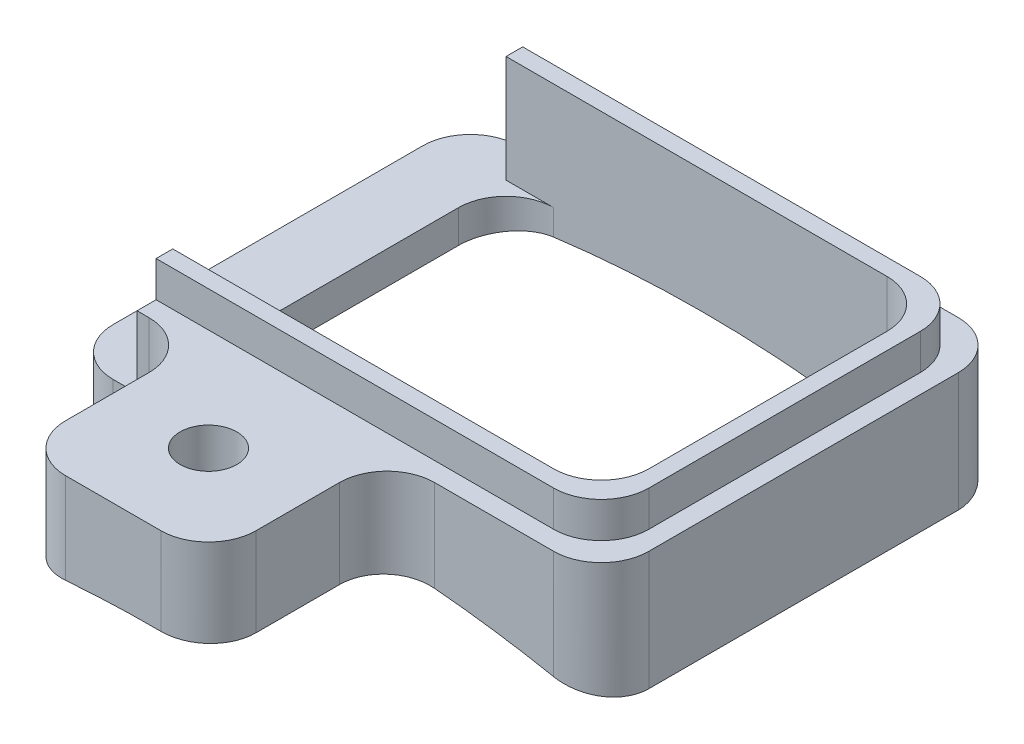
from build123d import *

# Parameters (mm, degrees)
SKETCH5_W                 = 11.25
SKETCH5_H                 = 8.5
EXTRUDE4_DEPTH            = 2.5
SKETCH19_W                = 1.5
SKETCH19_H                = 8.5
EXTRUDE12_DEPTH           = 1.5
SKETCH21_W                = 9
SKETCH21_H                = 7
EXTRUDE13_DEPTH           = 3.5
SKETCH22_W                = 4
SKETCH22_H                = 2.302396537
EXTRUDE14_DEPTH           = 3.75
EXTRUDE15_DEPTH           = 0.75
EXTRUDE18_DEPTH           = 13.25
F_0_80_TAPPED_HOLE1_D     = 1.19126
F_0_80_TAPPED_HOLE1_DEPTH = 79.01
F_0_80_TAPPED_HOLE1_TIP   = 0.357890611
FILLET4_R                 = 1


with BuildPart() as part:
    # Sketch5 → Extrude4 (new body)
    with BuildSketch(Plane(origin=(0, 0, 0), x_dir=(1, 0, 0), z_dir=(0, 1, 0))):
        Rectangle(SKETCH5_W, SKETCH5_H)
    extrude(amount=EXTRUDE4_DEPTH)

    # Sketch19 → Extrude12 (cut)
    with BuildSketch(Plane(origin=(0, 2.5, 0), x_dir=(-1, 0, 0), z_dir=(0, 1, 0))):
        with Locations((4.875, 0)):
            Rectangle(SKETCH19_W, SKETCH19_H)
    extrude(amount=-EXTRUDE12_DEPTH, mode=Mode.SUBTRACT)

    # Sketch21 → Extrude13 (cut, through all)
    with BuildSketch(Plane(origin=(0, 2.5, 0), x_dir=(-1, 0, 0), z_dir=(0, 1, 0))):
        with Locations((-0.375, 0)):
            Rectangle(SKETCH21_W, SKETCH21_H)
    extrude(amount=-EXTRUDE13_DEPTH, mode=Mode.SUBTRACT)

    # Sketch22 → Extrude14 (add)
    with BuildSketch(Plane.XY.offset(4.25)):
        with Locations((-0.875, 1.348801732)):
            Rectangle(SKETCH22_W, SKETCH22_H)
    extrude(amount=EXTRUDE14_DEPTH)

    # Sketch24 → Extrude15 (add)
    with BuildSketch(Plane(origin=(0, 2.5, 0), x_dir=(1, 0, 0), z_dir=(0, 1, 0))):
        Polygon((-4.125, 3.85), (-4.125, 3.5), (4.875, 3.5), (4.875, -3.5), (-4.125, -3.5), (-4.125, -3.85), (5.225, -3.85), (5.225, 3.85), align=None)
    extrude(amount=EXTRUDE15_DEPTH)

    # Sketch33 → Extrude18 (cut, through all)
    with BuildSketch(Plane(origin=(0, 0, -4.25), x_dir=(-1, 0, 0), z_dir=(0, 0, -1))):
        with BuildLine():
            Line((38.114202873, -7.832830513), (5.625, 0))
            ThreePointArc((5.625, 0), (0, 0.668489655), (-5.625, 0))
            Line((-5.625, 0), (-38.114202873, -7.832830513))
            Line((-38.114202873, -7.832830513), (-38.114202873, -74.672984228))
            Line((-38.114202873, -74.672984228), (38.114202873, -74.672984228))
            Line((38.114202873, -74.672984228), (38.114202873, -7.832830513))
        make_face()
    extrude(amount=-EXTRUDE18_DEPTH, mode=Mode.SUBTRACT)

    # #0-80 Tapped Hole1
    with Locations(Plane(origin=(-0.875, 2.5, 6), x_dir=(0, 0, 1), z_dir=(0, 1, 0))):
        with Locations((0, 0)):
            Hole(F_0_80_TAPPED_HOLE1_D / 2, depth=F_0_80_TAPPED_HOLE1_DEPTH)
            with Locations((0, 0, -(F_0_80_TAPPED_HOLE1_DEPTH + F_0_80_TAPPED_HOLE1_TIP / 2))):  # 118° drill point
                Cone(0, F_0_80_TAPPED_HOLE1_D / 2, F_0_80_TAPPED_HOLE1_TIP, mode=Mode.SUBTRACT)

    # Fillet4
    fillet4_edges = [part.edges().sort_by_distance(p)[0] for p in [
        (5.625, 1.25, -4.25),
        (5.225, 2.875, -3.85),
        (5.625, 1.25, 4.25),
        (5.225, 2.875, 3.85),
        (4.875, 1.709078603, 3.5),
        (4.875, 1.709078603, -3.5),
        (-4.125, 0.655670027, 3.5),
        (-4.125, 0.655670027, -3.5),
        (-5.625, 0.5, -4.25),
        (-5.625, 0.5, 4.25),
        (-2.875, 1.497833445, 4.25),
        (-2.875, 1.497833445, 8),
        (1.125, 1.571053984, 8),
        (1.125, 1.571053984, 4.25),
    ]]
    fillet(fillet4_edges, radius=FILLET4_R)


solid = part.part
